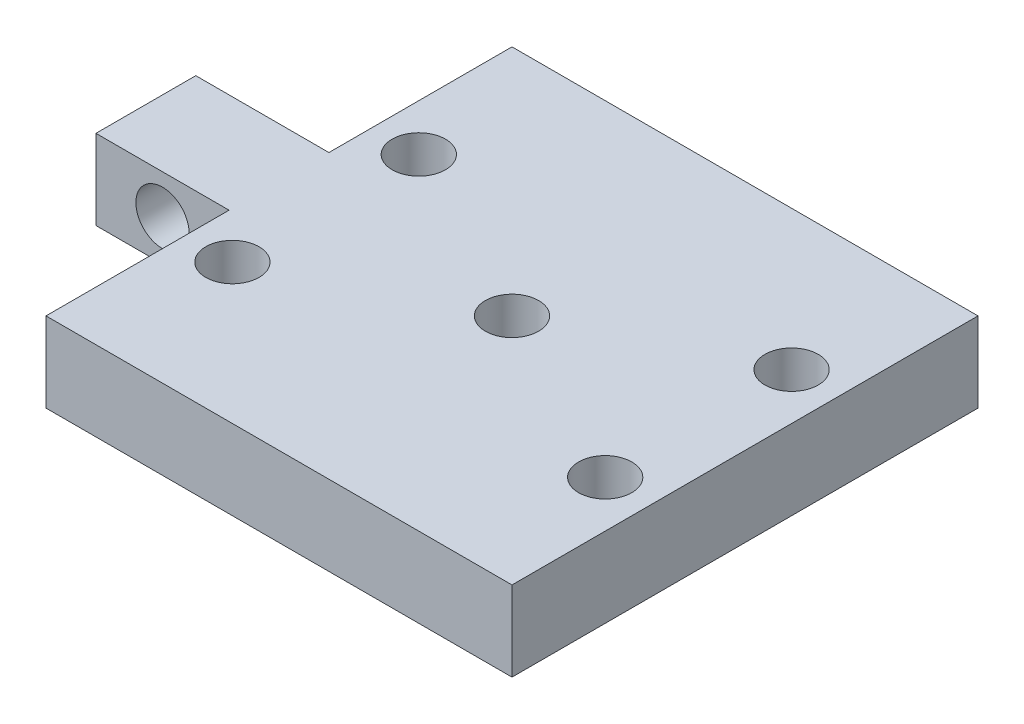
from build123d import *

# Parameters (mm, degrees)
CROQUIS1_W              = 70
CROQUIS1_H              = 70
CROQUIS1_R              = 4
SALIENTE_EXTRUIR1_DEPTH = 12
CROQUIS3_R              = 4
CORTAR_EXTRUIR2_DEPTH   = 15
CROQUIS4_W              = 40
CROQUIS4_H              = 15
SALIENTE_EXTRUIR2_DEPTH = 12
CROQUIS6_R              = 4
CORTAR_EXTRUIR4_DEPTH   = 15


with BuildPart() as part:
    # Croquis1 → Saliente-Extruir1 (new body)
    with BuildSketch(Plane(origin=(0, 0, 0), x_dir=(1, 0, 0), z_dir=(0, 1, 0))):
        Rectangle(CROQUIS1_W, CROQUIS1_H)
        Circle(CROQUIS1_R, mode=Mode.SUBTRACT)
    extrude(amount=SALIENTE_EXTRUIR1_DEPTH)

    # Croquis3 → Cortar-Extruir2 (cut)
    with BuildSketch(Plane(origin=(0, 12, 0), x_dir=(1, 0, 0), z_dir=(0, 1, 0))):
        with Locations((-28, 14)):
            Circle(CROQUIS3_R)
        with Locations((28, 14)):
            Circle(CROQUIS3_R)
        with Locations((28, -14)):
            Circle(CROQUIS3_R)
        with Locations((-28, -14)):
            Circle(CROQUIS3_R)
    extrude(amount=-CORTAR_EXTRUIR2_DEPTH, mode=Mode.SUBTRACT)

    # Croquis4 → Saliente-Extruir2 (add)
    with BuildSketch(Plane(origin=(0, 12, 0), x_dir=(1, 0, 0), z_dir=(0, 1, 0))):
        with Locations((-35, 0)):
            Rectangle(CROQUIS4_W, CROQUIS4_H)
    extrude(amount=-SALIENTE_EXTRUIR2_DEPTH)

    # Croquis6 → Cortar-Extruir4 (cut)
    with BuildSketch(Plane.XY.offset(7.5)):
        with Locations((-45, 6)):
            Circle(CROQUIS6_R)
    extrude(amount=-CORTAR_EXTRUIR4_DEPTH, mode=Mode.SUBTRACT)


solid = part.part
